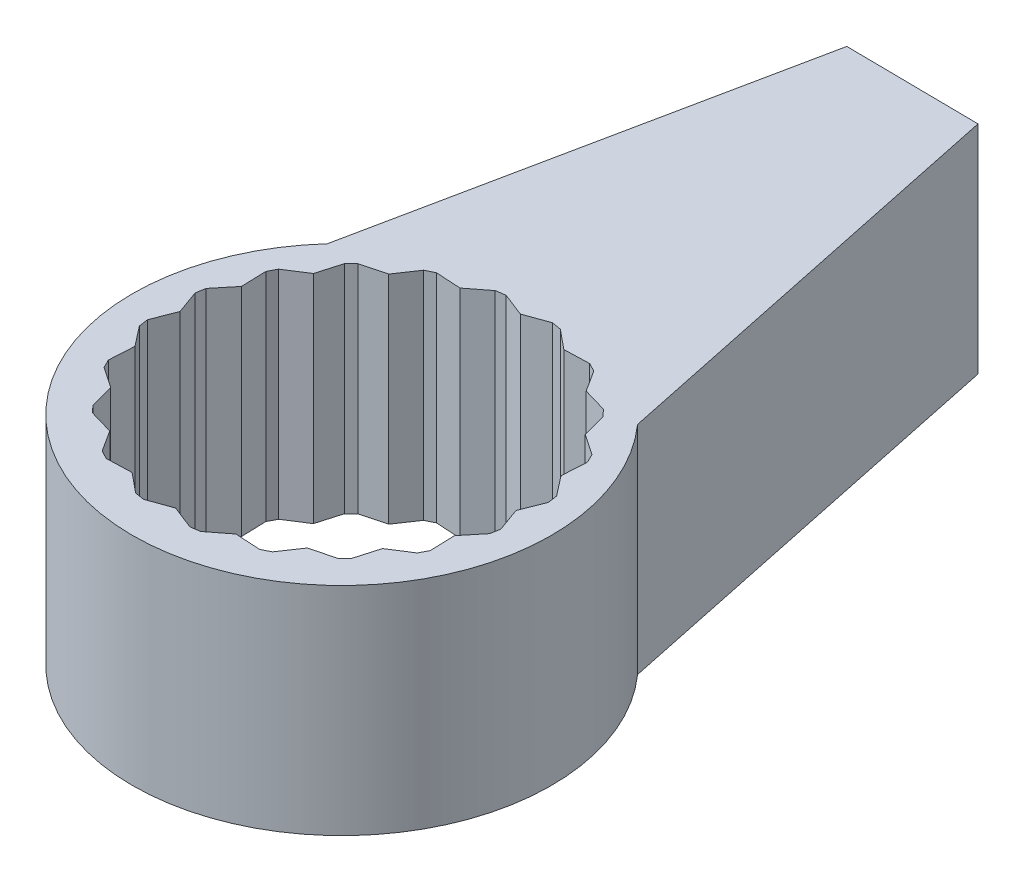
from build123d import *

# Parameters (mm, degrees)
Y_KSEKLIK_EKSTR_ZYON1_DEPTH = 3
KES_EKSTR_ZYON1_DEPTH       = 3


with BuildPart() as part:
    # Çizim2 → Yükseklik-Ekstrüzyon1 (new body)
    with BuildSketch(Plane(origin=(0, 0, 0), x_dir=(1, 0, 0), z_dir=(0, 1, 0))):
        with BuildLine():
            Line((-2.149165658, 1.947071384), (-0.918653313, 7.910801403))
            Line((-0.918653313, 7.910801403), (0.918505018, 7.890194196))
            Line((0.918505018, 7.890194196), (2.165891081, 1.928449073))
            ThreePointArc((2.165891081, 1.928449073), (-0.012515293, -2.899972994), (-2.149165658, 1.947071384))
        make_face()
    extrude(amount=Y_KSEKLIK_EKSTR_ZYON1_DEPTH)

    # Çizim3 → Kes-Ekstrüzyon1 (cut)
    with BuildSketch(Plane(origin=(0, 3, -0.083225357), x_dir=(1, 0, 0), z_dir=(0, 1, 0))):
        Polygon((-1.696920921, 1.837383666), (-1.792135812, 1.744599792), (-1.88879277, 1.410713864), (-2.181417312, 1.223115215), (-2.243300262, 1.105449488), (-2.232050065, 0.758036458), (-2.452381372, 0.489193583), (-2.474874845, 0.358163944), (-2.356818742, 0.031231019), (-2.48328925, -0.292539866), (-2.464191429, -0.424107324), (-2.250885573, -0.69855767), (-2.271115468, -1.045563617), (-2.212295781, -1.164790154), (-1.924620035, -1.359892809), (-1.836629074, -1.696166458), (-1.743845201, -1.791381349), (-1.409959273, -1.888038307), (-1.222360623, -2.180662849), (-1.104694896, -2.242545799), (-0.757281866, -2.231295602), (-0.488438992, -2.451626909), (-0.357409352, -2.474120382), (-0.030476428, -2.356064279), (0.293294458, -2.482534787), (0.424861916, -2.463436966), (0.699312262, -2.25013111), (1.046318209, -2.270361005), (1.165544745, -2.211541317), (1.360647401, -1.923865572), (1.696921049, -1.835874611), (1.792135941, -1.743090737), (1.888792899, -1.409204809), (2.181417441, -1.22160616), (2.24330039, -1.103940433), (2.232050194, -0.756527403), (2.4523815, -0.487684528), (2.474874973, -0.356654889), (2.35681887, -0.029721965), (2.483289379, 0.294048921), (2.464191557, 0.425616379), (2.250885702, 0.700066725), (2.271115596, 1.047072672), (2.212295909, 1.166299208), (1.924620164, 1.361401864), (1.836629202, 1.697675512), (1.743845329, 1.792890404), (1.409959401, 1.889547362), (1.222360751, 2.182171904), (1.104695025, 2.244054853), (0.757281994, 2.232804657), (0.48843912, 2.453135964), (0.357409481, 2.475629437), (0.030476556, 2.357573334), (-0.29329433, 2.484043842), (-0.424861787, 2.464946021), (-0.699312133, 2.251640165), (-1.04631808, 2.27187006), (-1.165544617, 2.213050372), (-1.360647273, 1.925374627), align=None)
    extrude(amount=-KES_EKSTR_ZYON1_DEPTH, mode=Mode.SUBTRACT)


solid = part.part
